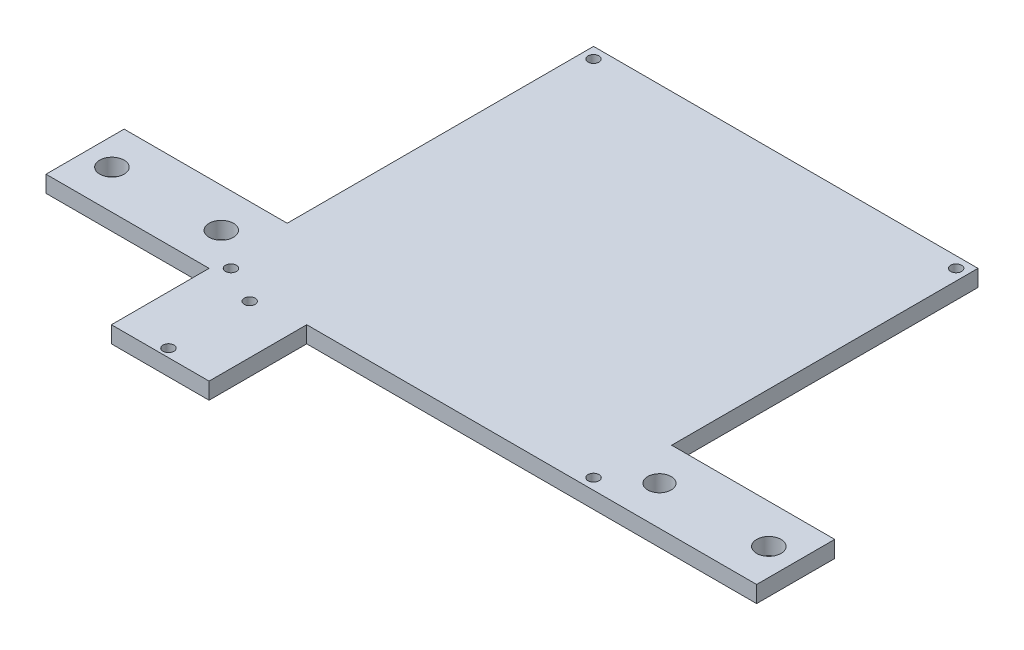
from build123d import *

# Parameters (mm, degrees)
SKETCH1_R           = 1.4224
SKETCH1_R_2         = 3.175
SKETCH1_R_3         = 3.048
BOSS_EXTRUDE2_DEPTH = 4.318


with BuildPart() as part:
    # Sketch1 → Boss-Extrude2 (new body)
    with BuildSketch(Plane(origin=(0, 0, 0), x_dir=(1, 0, 0), z_dir=(0, 1, 0))):
        Polygon((0, 20.32), (0, 100), (100, 100), (100, 20.32), (142.418, 20.32), (142.418, 0), (100, 0), (25.4, 0), (25.4, -25.4), (0, -25.4), (0, 0), (-42.418, 0), (-42.418, 20.32), align=None)
        with Locations((2.8448, 2.8448)):
            Circle(SKETCH1_R, mode=Mode.SUBTRACT)
        with Locations((97.1552, 2.8448)):
            Circle(SKETCH1_R, mode=Mode.SUBTRACT)
        with Locations((2.8448, 97.1552)):
            Circle(SKETCH1_R, mode=Mode.SUBTRACT)
        with Locations((97.1552, 97.1552)):
            Circle(SKETCH1_R, mode=Mode.SUBTRACT)
        with Locations((12.7, -23.2664)):
            Circle(SKETCH1_R, mode=Mode.SUBTRACT)
        with Locations((12.7, -2.1336)):
            Circle(SKETCH1_R, mode=Mode.SUBTRACT)
        with Locations((-6.985, 10.16)):
            Circle(SKETCH1_R_2, mode=Mode.SUBTRACT)
        with Locations((-35.433, 10.16)):
            Circle(SKETCH1_R_2, mode=Mode.SUBTRACT)
        with Locations((106.985, 10.16)):
            Circle(SKETCH1_R_3, mode=Mode.SUBTRACT)
        with Locations((135.433, 10.16)):
            Circle(SKETCH1_R_2, mode=Mode.SUBTRACT)
    extrude(amount=BOSS_EXTRUDE2_DEPTH)


solid = part.part
